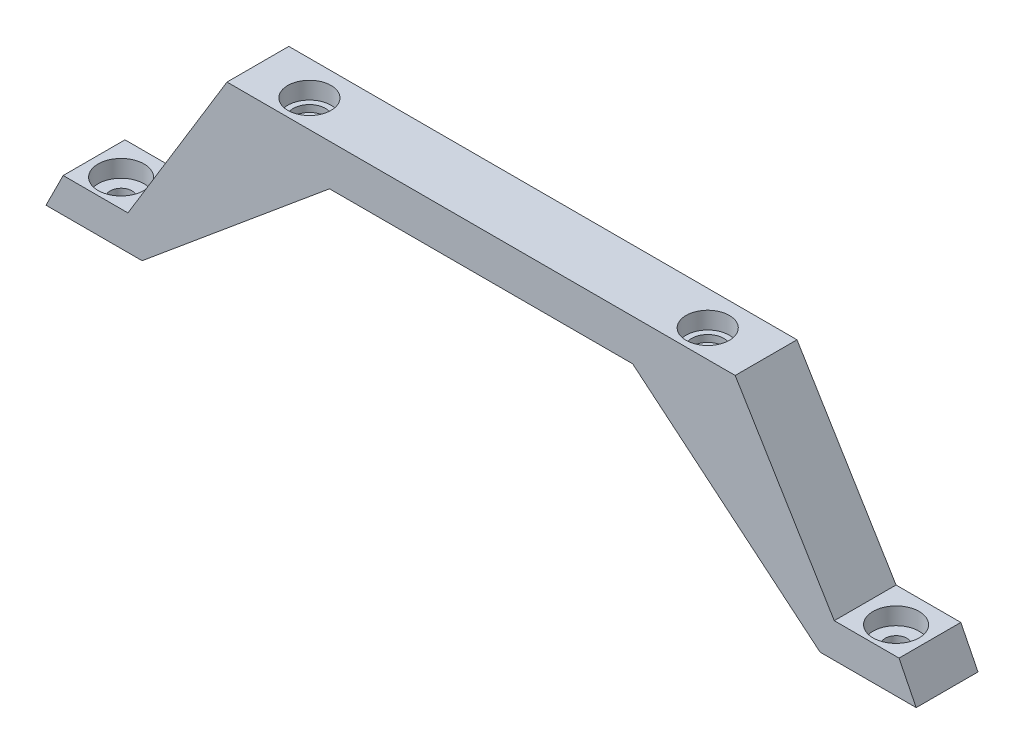
from build123d import *

# Parameters (mm, degrees)
EXTRUDE_1_DEPTH     = 10
SKETCH_7_R          = 1.55
CUT_EXTRUDE_1_DEPTH = 26.214157215
CUT_EXTRUDE_2_DEPTH = 8.5
SKETCH_10_R         = 1.575
CUT_EXTRUDE_4_DEPTH = 12
SKETCH_11_R         = 3.35
CUT_EXTRUDE_5_DEPTH = 2.5
SKETCH_12_W         = 126.714157214
SKETCH_12_H         = 1
CUT_EXTRUDE_6_DEPTH = 29.714157215


with BuildPart() as part:
    # 草图1 → 凸台-拉伸1 (new body)
    with BuildSketch(Plane.XY):
        Polygon((-3.188712924, 13.052848472), (33.811287076, 13.052848472), (33.811287076, 7.052848472), (15.60198174, 7.052848472), (11.74198174, 7.052848472), (-15.549299656, -15.661308743), (-23.688712924, -15.661308743), (-27.545791531, -15.661308743), (-29.545791531, -15.661308743), (-27.045791531, -10.661308743), (-25.045791531, -10.661308743), (-17.614428715, -10.661308743), align=None)
    extrude_1 = extrude(amount=EXTRUDE_1_DEPTH)

    # 镜向1: 凸台-拉伸1 across plane
    add(extrude_1.mirror(Plane(origin=(33.811287076, 13.052848472, 10), x_dir=(0, 0, 1), z_dir=(-1, 0, 0))))

    # 草图5 → 切除-旋转7 (revolve, cut)
    with BuildSketch(Plane.XY.offset(5)):
        Polygon((7.961287076, 13.052848472), (7.961287076, 10.552848472), (7.161287076, 10.552848472), (7.161287076, 9.552848472), (6.361287076, 9.552848472), (4.811287076, 9.552848472), (4.811287076, 13.052848472), align=None)
    cut_revolve_7 = revolve(axis=Axis((4.811287076, 9.552848472, 5), (0, 1, 0)), mode=Mode.SUBTRACT)

    # 草图7 → 切除-拉伸1 (cut, through all)
    with BuildSketch(Plane(origin=(0, 9.552848472, 0), x_dir=(1, 0, 0), z_dir=(0, 1, 0))):
        with Locations((4.811287076, -5)):
            Circle(SKETCH_7_R)
    cut_extrude_1 = extrude(amount=-CUT_EXTRUDE_1_DEPTH, mode=Mode.SUBTRACT)

    # 草图8 → 切除-拉伸2 (cut)
    with BuildSketch(Plane(origin=(0, -1.947151528, 0), x_dir=(1, 0, 0), z_dir=(0, 1, 0))):
        Polygon((8.333123718, -5), (6.572205397, -1.95), (3.050368755, -1.95), (1.289450434, -5), (3.050368755, -8.05), (6.572205397, -8.05), align=None)
    cut_extrude_2 = extrude(amount=CUT_EXTRUDE_2_DEPTH, mode=Mode.SUBTRACT)

    # 草图10 → 切除-拉伸4 (cut)
    with BuildSketch(Plane(origin=(0, -10.661308743, 0), x_dir=(1, 0, 0), z_dir=(0, 1, 0))):
        with Locations((-22.614428715, -5)):
            Circle(SKETCH_10_R)
    cut_extrude_4 = extrude(amount=-CUT_EXTRUDE_4_DEPTH, mode=Mode.SUBTRACT)

    # 草图11 → 切除-拉伸5 (cut)
    with BuildSketch(Plane(origin=(0, -10.661308743, 0), x_dir=(1, 0, 0), z_dir=(0, 1, 0))):
        with Locations((-22.614428715, -5)):
            Circle(SKETCH_11_R)
    cut_extrude_5 = extrude(amount=-CUT_EXTRUDE_5_DEPTH, mode=Mode.SUBTRACT)

    # 镜向2: 切除-旋转7, 切除-拉伸1, 切除-拉伸2, 切除-拉伸4, 切除-拉伸5 across plane
    add(cut_revolve_7.mirror(Plane(origin=(33.811287076, 0, 0), x_dir=(0, 0, 1), z_dir=(1, 0, 0))), mode=Mode.SUBTRACT)
    add(cut_extrude_1.mirror(Plane(origin=(33.811287076, 0, 0), x_dir=(0, 0, 1), z_dir=(1, 0, 0))), mode=Mode.SUBTRACT)
    add(cut_extrude_2.mirror(Plane(origin=(33.811287076, 0, 0), x_dir=(0, 0, 1), z_dir=(1, 0, 0))), mode=Mode.SUBTRACT)
    add(cut_extrude_4.mirror(Plane(origin=(33.811287076, 0, 0), x_dir=(0, 0, 1), z_dir=(1, 0, 0))), mode=Mode.SUBTRACT)
    add(cut_extrude_5.mirror(Plane(origin=(33.811287076, 0, 0), x_dir=(0, 0, 1), z_dir=(1, 0, 0))), mode=Mode.SUBTRACT)

    # 草图12 → 切除-拉伸6 (cut, through all)
    with BuildSketch(Plane(origin=(0, 13.052848472, 0), x_dir=(1, 0, 0), z_dir=(0, 1, 0))):
        with Locations((33.811287076, -9.5)):
            Rectangle(SKETCH_12_W, SKETCH_12_H)
    extrude(amount=-CUT_EXTRUDE_6_DEPTH, mode=Mode.SUBTRACT)


solid = part.part
